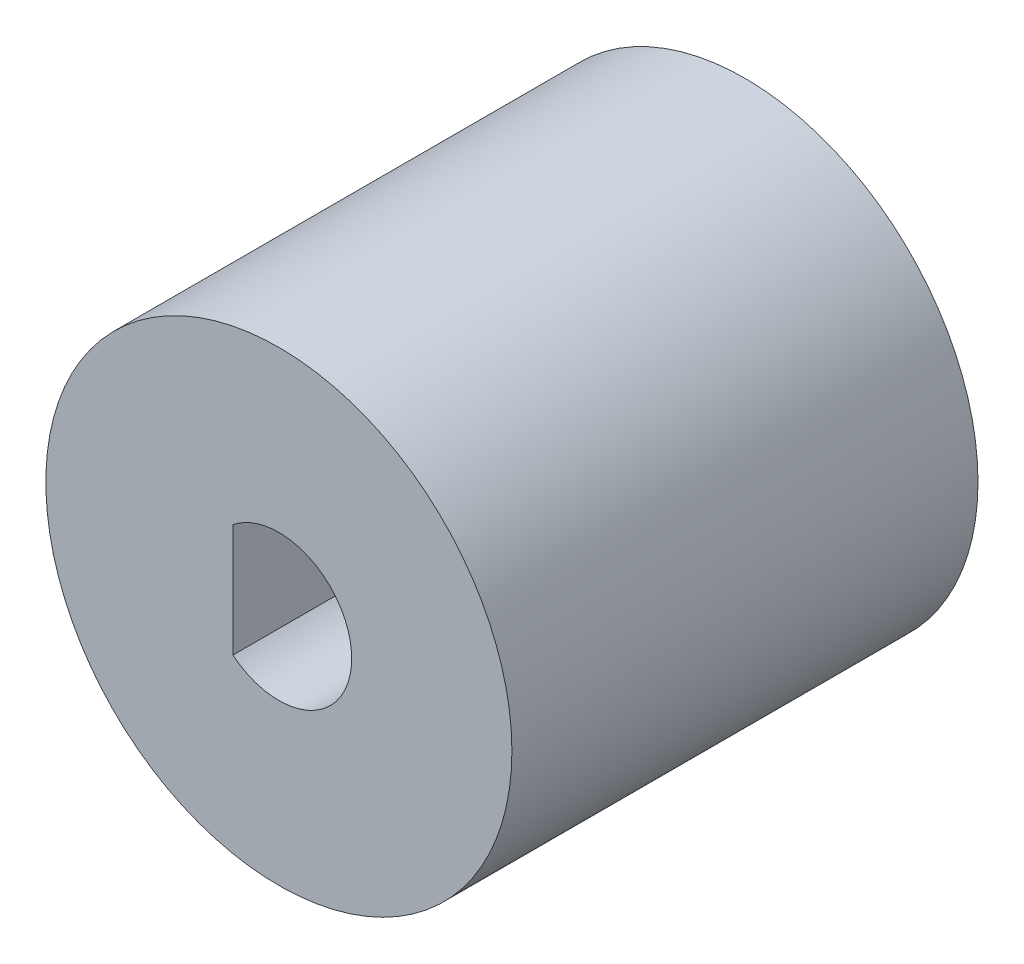
from build123d import *

# Parameters (mm, degrees)
SKETCH_1_R          = 8
EXTRUDE_1_DEPTH     = 16
CUT_EXTRUDE_1_DEPTH = 8
CUT_EXTRUDE_2_DEPTH = 8


with BuildPart() as part:
    # 草图1 → 凸台-拉伸1 (new body)
    with BuildSketch(Plane.XY):
        Circle(SKETCH_1_R)
    extrude(amount=EXTRUDE_1_DEPTH)

    # 草图2 → 切除-拉伸1 (cut)
    with BuildSketch(Plane(origin=(0, 0, 0), x_dir=(-1, 0, 0), z_dir=(0, 0, -1))):
        with BuildLine():
            Line((3.020550217, 2.622265506), (3.020550217, -2.622265506))
            ThreePointArc((3.020550217, -2.622265506), (-4, 0), (3.020550217, 2.622265506))
        make_face()
    extrude(amount=-CUT_EXTRUDE_1_DEPTH, mode=Mode.SUBTRACT)

    # 草图3 → 切除-拉伸2 (cut)
    with BuildSketch(Plane.XY.offset(16)):
        with BuildLine():
            Line((-1.578947526, -1.938278801), (-1.578947526, 1.938278801))
            ThreePointArc((-1.578947526, 1.938278801), (2.5, 0), (-1.578947526, -1.938278801))
        make_face()
    extrude(amount=-CUT_EXTRUDE_2_DEPTH, mode=Mode.SUBTRACT)


solid = part.part
